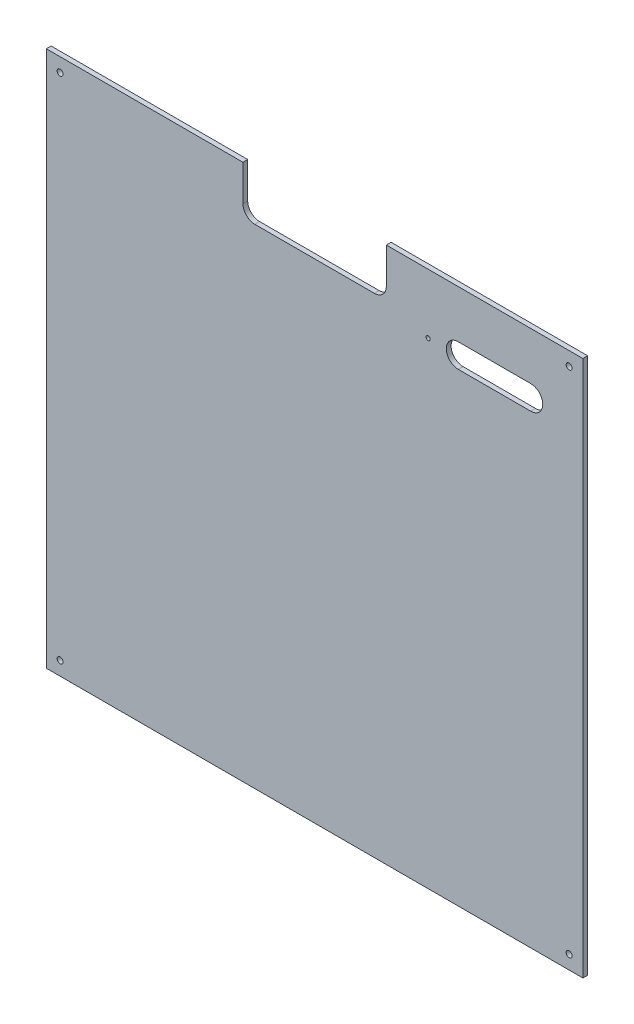
from build123d import *

# Parameters (mm, degrees)
SCHIZZO1_R                   = 2.5
SCHIZZO1_R_2                 = 1.75
ESTRUSIONE_ESTRUSIONE1_DEPTH = 4


with BuildPart() as part:
    # Schizzo1 → Estrusione-Estrusione1 (new body)
    with BuildSketch(Plane.XY):
        with BuildLine():
            Line((0, 0), (0, 449))
            Line((0, 449), (164.5, 449))
            Line((164.5, 449), (164.5, 419))
            ThreePointArc((164.5, 419), (167.428932188, 411.928932188), (174.5, 409))
            Line((174.5, 409), (274.5, 409))
            ThreePointArc((274.5, 409), (281.571067812, 411.928932188), (284.5, 419))
            Line((284.5, 419), (284.5, 449))
            Line((284.5, 449), (449, 449))
            Line((449, 449), (449, 0))
            Line((449, 0), (0, 0))
        make_face()
        with Locations((11.5, 11.5)):
            Circle(SCHIZZO1_R, mode=Mode.SUBTRACT)
        with Locations((437.5, 11.5)):
            Circle(SCHIZZO1_R, mode=Mode.SUBTRACT)
        with Locations((437.5, 437.5)):
            Circle(SCHIZZO1_R, mode=Mode.SUBTRACT)
        with Locations((11.5, 437.5)):
            Circle(SCHIZZO1_R, mode=Mode.SUBTRACT)
        with Locations((319.5, 399)):
            Circle(SCHIZZO1_R_2, mode=Mode.SUBTRACT)
        with BuildLine():
            Line((344.715899345, 409), (405.440355678, 409))
            ThreePointArc((405.440355678, 409), (415.440355678, 399), (405.440355678, 389))
            Line((405.440355678, 389), (344.715899345, 389))
            ThreePointArc((344.715899345, 389), (334.715899345, 399), (344.715899345, 409))
        make_face(mode=Mode.SUBTRACT)
    extrude(amount=ESTRUSIONE_ESTRUSIONE1_DEPTH)


solid = part.part
